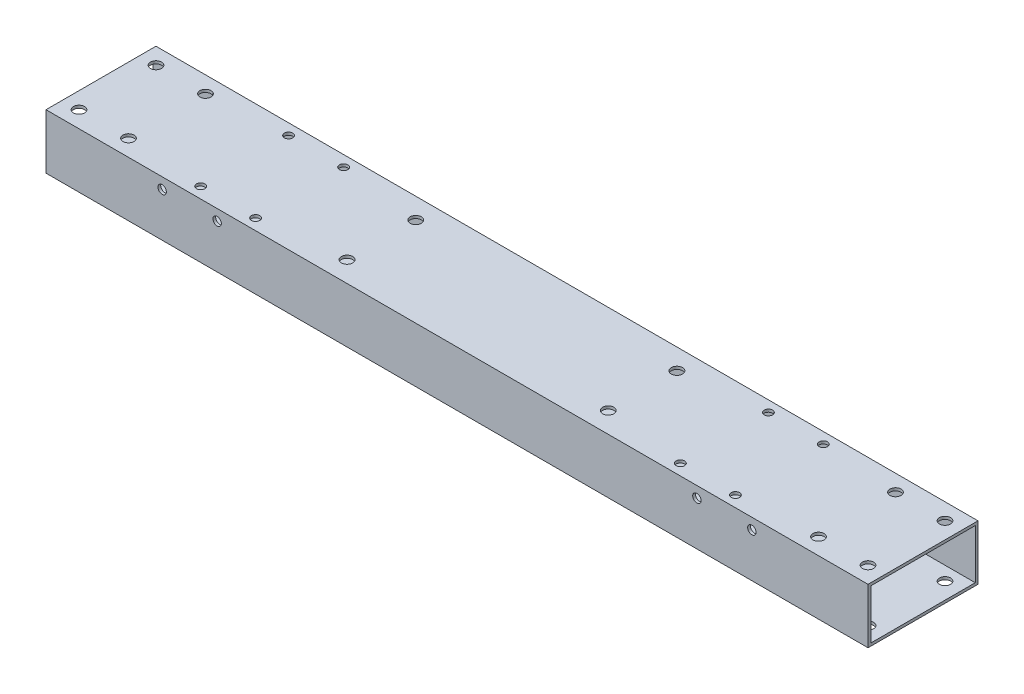
from build123d import *

# Parameters (mm, degrees)
SKETCH_1_W          = 40
SKETCH_1_H          = 20
EXTRUDE_1_DEPTH     = 149.5
SKETCH_2_W          = 38
SKETCH_2_H          = 18
CUT_EXTRUDE_1_DEPTH = 2999
SKETCH_4_R          = 2.05
CUT_EXTRUDE_2_DEPTH = 2999
SKETCH_5_R          = 2.025
CUT_EXTRUDE_3_DEPTH = 2999
CUT_EXTRUDE_START   = -21
SKETCH_6_R          = 1.525
CUT_EXTRUDE_4_DEPTH = 22
CUT_EXTRUDE_START_2 = -41
SKETCH_8_R          = 1.525
CUT_EXTRUDE_5_DEPTH = 42


with BuildPart() as part:
    # 草图1 → 凸台-拉伸1 (new body, symmetric)
    with BuildSketch(Plane(origin=(0, 0, 0), x_dir=(0, 0, -1), z_dir=(1, 0, 0))):
        Rectangle(SKETCH_1_W, SKETCH_1_H)
    extrude(amount=EXTRUDE_1_DEPTH, both=True)

    # 草图2 → 切除-拉伸1 (cut)
    with BuildSketch(Plane.ZY.offset(149.5)):
        Rectangle(SKETCH_2_W, SKETCH_2_H)
    extrude(amount=-CUT_EXTRUDE_1_DEPTH, mode=Mode.SUBTRACT)

    # 草图4 → 切除-拉伸2 (cut)
    with BuildSketch(Plane(origin=(0, 10, 0), x_dir=(1, 0, 0), z_dir=(0, 1, 0))):
        with Locations((-47.5, 12.5)):
            Circle(SKETCH_4_R)
        with Locations((-47.5, -12.5)):
            Circle(SKETCH_4_R)
        with Locations((47.5, 12.5)):
            Circle(SKETCH_4_R)
        with Locations((47.5, -12.5)):
            Circle(SKETCH_4_R)
    extrude(amount=-CUT_EXTRUDE_2_DEPTH, mode=Mode.SUBTRACT)

    # 草图5 → 切除-拉伸3 (cut)
    with BuildSketch(Plane.XZ.offset(10)):
        with Locations((-125.5, 14)):
            Circle(SKETCH_5_R)
        with Locations((-125.5, -14)):
            Circle(SKETCH_5_R)
        with Locations((-143.5, -14)):
            Circle(SKETCH_5_R)
        with Locations((-143.5, 14)):
            Circle(SKETCH_5_R)
    cut_extrude_3 = extrude(amount=-CUT_EXTRUDE_3_DEPTH, mode=Mode.SUBTRACT)

    # 镜向1: 切除-拉伸3 across plane
    add(cut_extrude_3.mirror(Plane(origin=(0, 0, 0), x_dir=(0, 0, 1), z_dir=(1, 0, 0))), mode=Mode.SUBTRACT)

    # 草图6 → 切除-拉伸4 (cut)
    with BuildSketch(Plane(origin=(0, 10, 0), x_dir=(1, 0, 0), z_dir=(0, 1, 0)).offset(CUT_EXTRUDE_START)):
        with Locations((-97.25, 16)):
            Circle(SKETCH_6_R)
        with Locations((-97.25, -16)):
            Circle(SKETCH_6_R)
        with Locations((-77.25, -16)):
            Circle(SKETCH_6_R)
        with Locations((-77.25, 16)):
            Circle(SKETCH_6_R)
    cut_extrude_4 = extrude(amount=CUT_EXTRUDE_4_DEPTH, mode=Mode.SUBTRACT)

    # 草图8 → 切除-拉伸5 (cut)
    with BuildSketch(Plane.XY.offset(20).offset(CUT_EXTRUDE_START_2)):
        with Locations((-107.25, 6)):
            Circle(SKETCH_8_R)
        with Locations((-87.25, 6)):
            Circle(SKETCH_8_R)
    cut_extrude_5 = extrude(amount=CUT_EXTRUDE_5_DEPTH, mode=Mode.SUBTRACT)

    # 镜向2: 切除-拉伸4, 切除-拉伸5 across plane
    add(cut_extrude_4.mirror(Plane(origin=(0, 0, 0), x_dir=(0, 0, 1), z_dir=(1, 0, 0))), mode=Mode.SUBTRACT)
    add(cut_extrude_5.mirror(Plane(origin=(0, 0, 0), x_dir=(0, 0, 1), z_dir=(1, 0, 0))), mode=Mode.SUBTRACT)


solid = part.part
